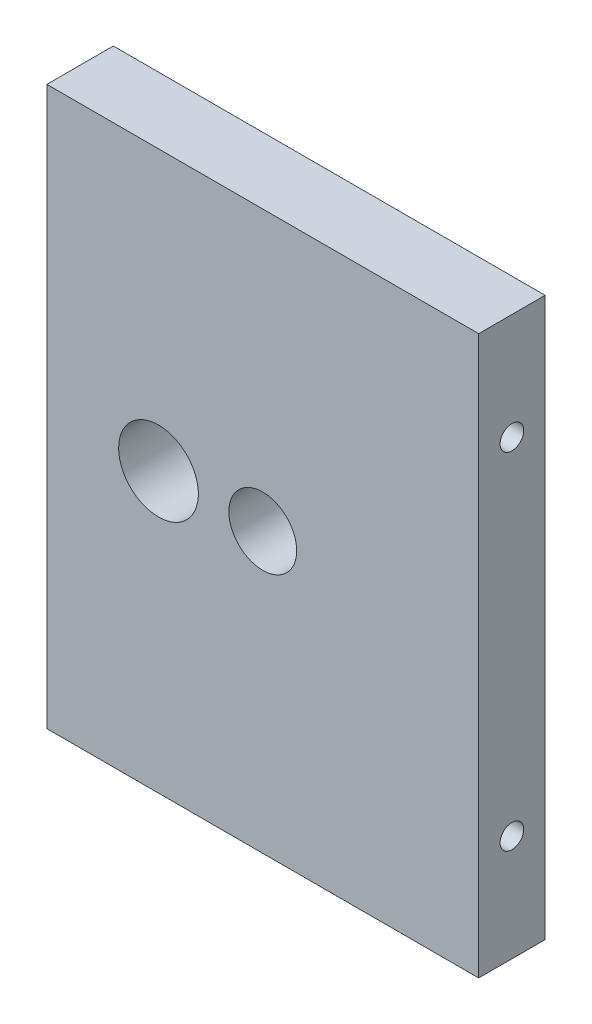
from build123d import *

# Parameters (mm, degrees)
SKETCH1_W                 = 32.5
SKETCH1_H                 = 42
BOSS_EXTRUDE2_DEPTH       = 5
F_2_56_TAPPED_HOLE1_D     = 1.778
F_2_56_TAPPED_HOLE1_DEPTH = 7.46583491
F_2_56_TAPPED_HOLE1_TIP   = 0.53416509
F_2_56_TAPPED_HOLE2_D     = 1.778
F_2_56_TAPPED_HOLE2_DEPTH = 7.46583491
F_2_56_TAPPED_HOLE2_TIP   = 0.53416509
CUT_EXTRUDE1_DEPTH        = 5
F_1_4_20_TAPPED_HOLE1_D   = 5.1054


with BuildPart() as part:
    # Sketch1 → Boss-Extrude2 (new body)
    with BuildSketch(Plane.XY):
        with Locations((16.25, 21)):
            Rectangle(SKETCH1_W, SKETCH1_H)
    extrude(amount=BOSS_EXTRUDE2_DEPTH)

    # #2-56 Tapped Hole1
    with Locations(Plane.ZY):
        with Locations((2.5, 34), (2.5, 8)):
            Hole(F_2_56_TAPPED_HOLE1_D / 2, depth=F_2_56_TAPPED_HOLE1_DEPTH)
            with Locations((0, 0, -(F_2_56_TAPPED_HOLE1_DEPTH + F_2_56_TAPPED_HOLE1_TIP / 2))):  # 118° drill point
                Cone(0, F_2_56_TAPPED_HOLE1_D / 2, F_2_56_TAPPED_HOLE1_TIP, mode=Mode.SUBTRACT)

    # #2-56 Tapped Hole2
    with Locations(Plane(origin=(32.5, 0, 0), x_dir=(0, 0, -1), z_dir=(1, 0, 0))):
        with Locations((-2.5, 34), (-2.5, 8)):
            Hole(F_2_56_TAPPED_HOLE2_D / 2, depth=F_2_56_TAPPED_HOLE2_DEPTH)
            with Locations((0, 0, -(F_2_56_TAPPED_HOLE2_DEPTH + F_2_56_TAPPED_HOLE2_TIP / 2))):  # 118° drill point
                Cone(0, F_2_56_TAPPED_HOLE2_D / 2, F_2_56_TAPPED_HOLE2_TIP, mode=Mode.SUBTRACT)

    # Sketch9 → Cut-Extrude1 (cut)
    with BuildSketch(Plane(origin=(0, 0, 0), x_dir=(-1, 0, 0), z_dir=(0, 0, -1))):
        with BuildLine():
            ThreePointArc((-11.4, 21), (-8.4, 18), (-5.4, 21))
            Line((-5.4, 21), (-8.4, 21))
            Line((-8.4, 21), (-11.4, 21))
        make_face()
        with BuildLine():
            Line((-8.4, 21), (-5.4, 21))
            ThreePointArc((-5.4, 21), (-8.4, 24), (-11.4, 21))
            Line((-11.4, 21), (-8.4, 21))
        make_face()
    extrude(amount=-CUT_EXTRUDE1_DEPTH, mode=Mode.SUBTRACT)

    # 1/4-20 Tapped Hole1 (through all)
    with Locations(Plane(origin=(0, 0, 0), x_dir=(-1, 0, 0), z_dir=(0, 0, -1))):
        with Locations((-16.25, 21)):
            Hole(F_1_4_20_TAPPED_HOLE1_D / 2)


solid = part.part
